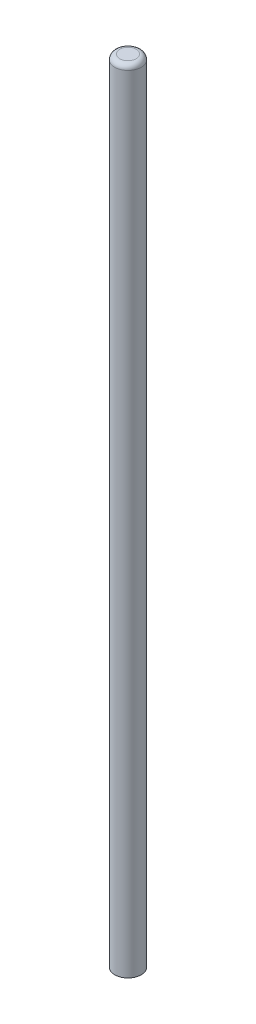
from build123d import *

# Parameters (mm, degrees)
SKETCH1_R           = 2
BOSS_EXTRUDE1_DEPTH = 120
FILLET1_R           = 0.75


with BuildPart() as part:
    # Sketch1 → Boss-Extrude1 (new body)
    with BuildSketch(Plane(origin=(0, 0, 0), x_dir=(1, 0, 0), z_dir=(0, 1, 0))):
        Circle(SKETCH1_R)
    extrude(amount=BOSS_EXTRUDE1_DEPTH)

    # Fillet1
    fillet1_edges = [part.edges().sort_by_distance(p)[0] for p in [
        (-2, 120, 0),
    ]]
    fillet(fillet1_edges, radius=FILLET1_R)


solid = part.part
